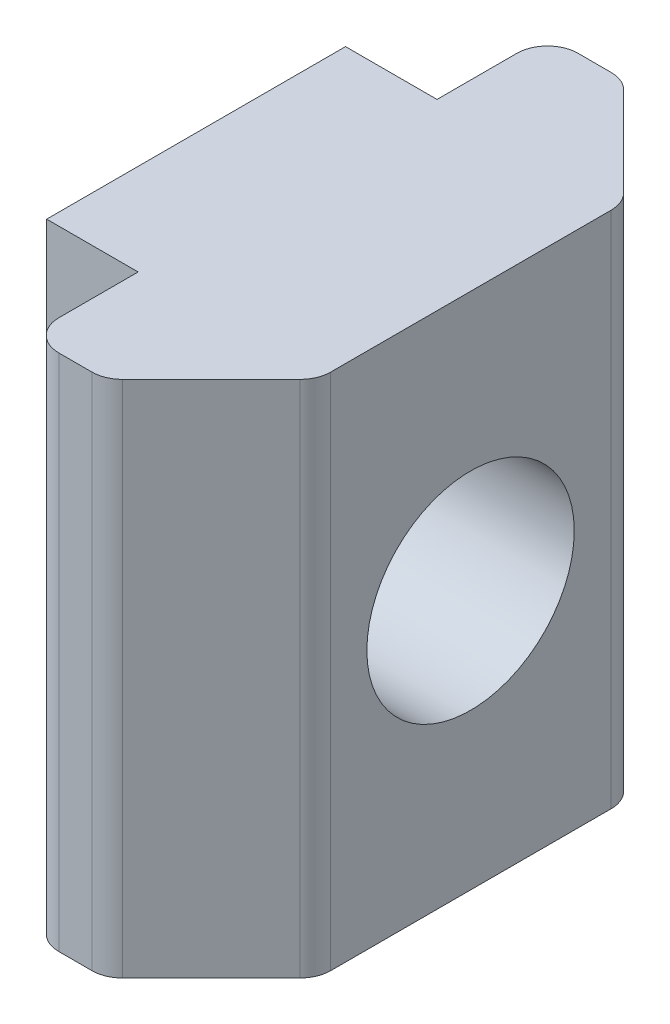
from build123d import *

# Parameters (mm, degrees)
BOSS_EXTRUDE1_DEPTH = 17
M8_TAPPED_HOLE1_D   = 6.8


with BuildPart() as part:
    # Sketch1 → Boss-Extrude1 (new body)
    with BuildSketch(Plane(origin=(0, 0, 0), x_dir=(1, 0, 0), z_dir=(0, 1, 0))):
        with BuildLine():
            Line((10.214282758, -18.266545266), (13.128495977, -15.352332485))
            ThreePointArc((13.128495977, -15.352332485), (13.345268844, -15.027908548), (13.421388977, -14.645224485))
            Line((13.421388977, -14.645224485), (13.421388977, -5.451641485))
            ThreePointArc((13.421388977, -5.451641485), (13.345268461, -5.068958498), (13.128495977, -4.744535485))
            Line((13.128495977, -4.744535485), (10.214282758, -1.830320704))
            ThreePointArc((10.214282758, -1.830320704), (9.889859409, -1.613547953), (9.507175977, -1.537427485))
            Line((9.507175977, -1.537427485), (8.421388977, -1.537427485))
            ThreePointArc((8.421388977, -1.537427485), (7.714282177, -1.830320722), (7.421388977, -2.537427537))
            Line((7.421388977, -2.537427537), (7.421388977, -5.159438485))
            Line((7.421388977, -5.159438485), (4.421388977, -5.159438485))
            Line((4.421388977, -5.159438485), (4.421388977, -14.959438485))
            Line((4.421388977, -14.959438485), (7.421388977, -14.959438485))
            Line((7.421388977, -14.959438485), (7.421388977, -17.559438537))
            ThreePointArc((7.421388977, -17.559438537), (7.714282276, -18.266545347), (8.421389151, -18.559438485))
            Line((8.421389151, -18.559438485), (9.507176151, -18.559438485))
            ThreePointArc((9.507176151, -18.559438485), (9.88985949, -18.483317984), (10.214282758, -18.266545266))
        make_face()
    extrude(amount=BOSS_EXTRUDE1_DEPTH)

    # M8 Tapped Hole1 (through all)
    with Locations(Plane(origin=(4.421388977, 8.5, 10.059438485), x_dir=(0, 0, -1), z_dir=(-1, 0, 0))):
        with Locations((0, 0)):
            Hole(M8_TAPPED_HOLE1_D / 2)


solid = part.part
